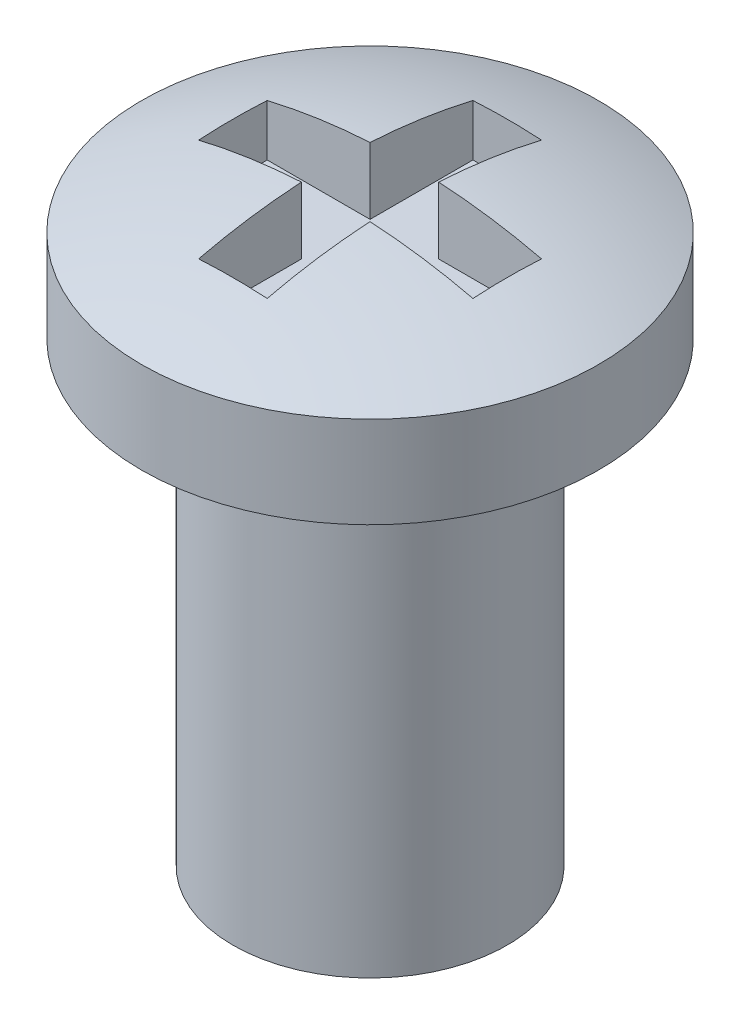
from build123d import *

# Parameters (mm, degrees)
SKETCH1_R           = 1.5
BOSS_EXTRUDE1_DEPTH = 5
SKETCH2_R           = 2.5
BOSS_EXTRUDE2_DEPTH = 1
DOME1_FACE_RADIUS   = 2.5
DOME1_HEIGHT        = 0.5
SKETCH3_W           = 1.125
SKETCH3_H           = 0.75
SKETCH3_W_2         = 0.75
SKETCH3_H_2         = 1.125
CUT_EXTRUDE1_DEPTH  = 0.75


with BuildPart() as part:
    # Sketch1 → Boss-Extrude1 (new body)
    with BuildSketch(Plane(origin=(0, 0, 0), x_dir=(1, 0, 0), z_dir=(0, 1, 0))):
        Circle(SKETCH1_R)
    extrude(amount=BOSS_EXTRUDE1_DEPTH)

    # Sketch2 → Boss-Extrude2 (add)
    with BuildSketch(Plane(origin=(0, 5, 0), x_dir=(1, 0, 0), z_dir=(0, 1, 0))):
        Circle(SKETCH2_R)
    extrude(amount=BOSS_EXTRUDE2_DEPTH)

    # Dome1: a dome of height H over a round flat face of radius A is a cap of a sphere of radius (A * A + H * H) / (2 * H)
    dome1_r = (DOME1_FACE_RADIUS * DOME1_FACE_RADIUS + DOME1_HEIGHT * DOME1_HEIGHT) / (2 * DOME1_HEIGHT)
    dome1_base = Plane((0, 6, 0), z_dir=(0, 1, 0))
    with Locations(dome1_base.offset(DOME1_HEIGHT - dome1_r)):
        dome1_ball = Sphere(dome1_r, mode=Mode.PRIVATE)
    add(split(dome1_ball, bisect_by=dome1_base, keep=Keep.TOP, mode=Mode.PRIVATE))

    # Sketch3 → Cut-Extrude1 (cut)
    with BuildSketch(Plane(origin=(0, 6.5, 0), x_dir=(1, 0, 0), z_dir=(0, 1, 0))):
        with Locations((-0.9375, 0)):
            Rectangle(SKETCH3_W, SKETCH3_H)
        Rectangle(SKETCH3_W_2, SKETCH3_H)
        with Locations((0, 0.9375)):
            Rectangle(SKETCH3_W_2, SKETCH3_H_2)
        with Locations((0.9375, 0)):
            Rectangle(SKETCH3_W, SKETCH3_H)
        with Locations((0, -0.9375)):
            Rectangle(SKETCH3_W_2, SKETCH3_H_2)
    extrude(amount=-CUT_EXTRUDE1_DEPTH, mode=Mode.SUBTRACT)


solid = part.part
